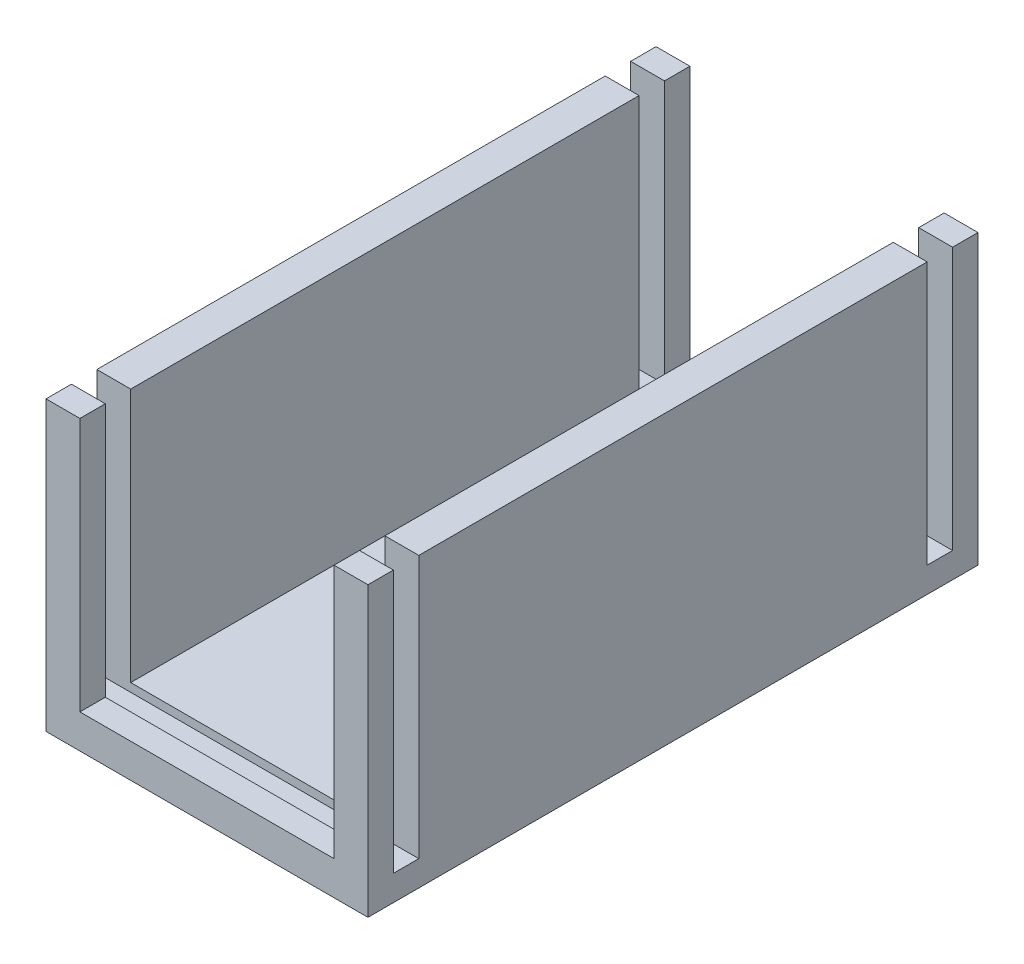
from build123d import *

# Parameters (mm, degrees)
SKETCH1_W           = 19
SKETCH1_H           = 17
BOSS_EXTRUDE1_DEPTH = 36
SKETCH2_W           = 15
SKETCH2_H           = 36
CUT_EXTRUDE1_DEPTH  = 15
SKETCH3_W           = 19
SKETCH3_H           = 1.5
CUT_EXTRUDE2_DEPTH  = 15.5


with BuildPart() as part:
    # Sketch1 → Boss-Extrude1 (new body)
    with BuildSketch(Plane.XY):
        Rectangle(SKETCH1_W, SKETCH1_H)
    extrude(amount=BOSS_EXTRUDE1_DEPTH)

    # Sketch2 → Cut-Extrude1 (cut)
    with BuildSketch(Plane(origin=(0, 8.5, 0), x_dir=(1, 0, 0), z_dir=(0, 1, 0))):
        with Locations((0, -18)):
            Rectangle(SKETCH2_W, SKETCH2_H)
    extrude(amount=-CUT_EXTRUDE1_DEPTH, mode=Mode.SUBTRACT)

    # Sketch3 → Cut-Extrude2 (cut)
    with BuildSketch(Plane(origin=(0, 8.5, 0), x_dir=(1, 0, 0), z_dir=(0, 1, 0))):
        with Locations((0, -33.75)):
            Rectangle(SKETCH3_W, SKETCH3_H)
        with Locations((0, -2.25)):
            Rectangle(SKETCH3_W, SKETCH3_H)
    extrude(amount=-CUT_EXTRUDE2_DEPTH, mode=Mode.SUBTRACT)


solid = part.part
